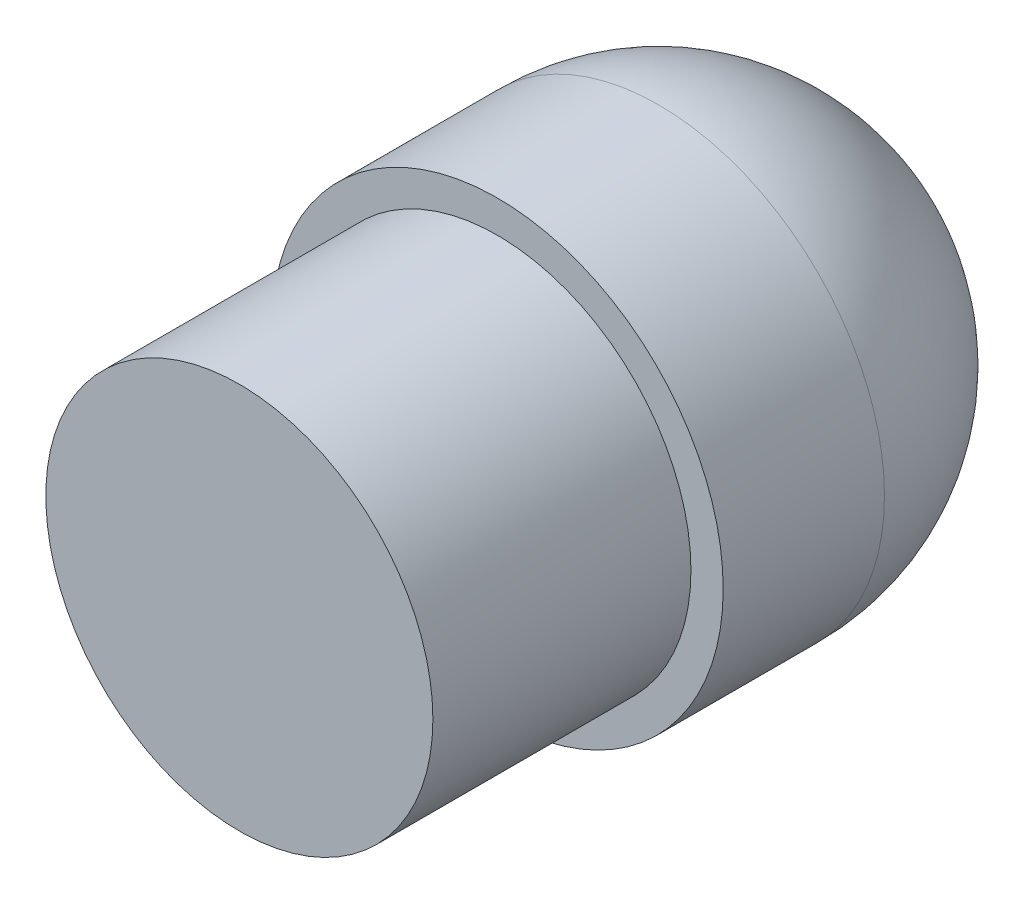
from build123d import *


with BuildPart() as part:
    # Croquis1 → Revolución1 (revolve)
    with BuildSketch(Plane(origin=(0, 0, 0), x_dir=(0, 0, -1), z_dir=(1, 0, 0))):
        with BuildLine():
            Line((0, 0), (0, 15))
            Line((0, 15), (20, 15))
            Line((20, 15), (20, 17.5))
            Line((20, 17.5), (32.5, 17.5))
            ThreePointArc((32.5, 17.5), (44.874368671, 12.374368671), (50, 0))
            Line((50, 0), (0, 0))
        make_face()
    revolve(axis=Axis((0, 0, 0), (0, 0, -1)))


solid = part.part
